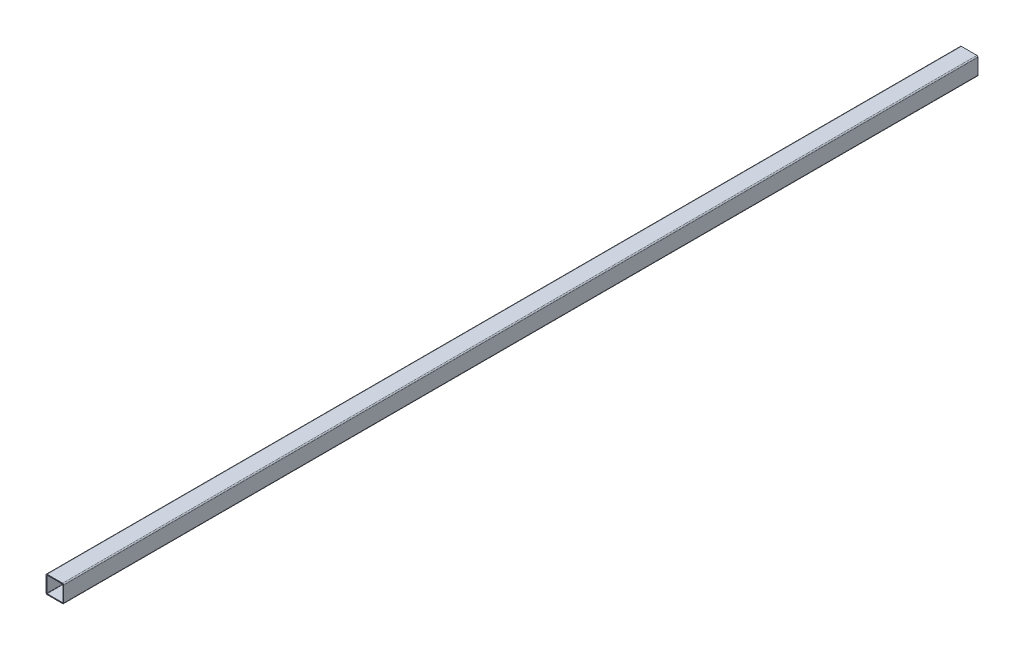
from build123d import *

# Parameters (mm, degrees)
BOSS_EXTRUDE1_DEPTH      = 825
BOSS_EXTRUDE1_DEPTH_BACK = 825


with BuildPart() as part:
    # Sketch1 → Boss-Extrude1 (new, two sides: drawn at the far end of the back side and taken through both)
    with BuildSketch(Plane.XY.offset(-BOSS_EXTRUDE1_DEPTH_BACK)):
        with BuildLine():
            Line((-14, -16), (14, -16))
            ThreePointArc((14, -16), (15.414213562, -15.414213562), (16, -14))
            Line((16, -14), (16, 14))
            ThreePointArc((16, 14), (15.414213562, 15.414213562), (14, 16))
            Line((14, 16), (-14, 16))
            ThreePointArc((-14, 16), (-15.414213562, 15.414213562), (-16, 14))
            Line((-16, 14), (-16, -14))
            ThreePointArc((-16, -14), (-15.414213562, -15.414213562), (-14, -16))
        make_face()
        with BuildLine():
            Line((-14, 14.48), (14, 14.48))
            ThreePointArc((14, 14.48), (14.339411255, 14.339411255), (14.48, 14))
            Line((14.48, 14), (14.48, -14))
            ThreePointArc((14.48, -14), (14.339411255, -14.339411255), (14, -14.48))
            Line((14, -14.48), (-14, -14.48))
            ThreePointArc((-14, -14.48), (-14.339411255, -14.339411255), (-14.48, -14))
            Line((-14.48, -14), (-14.48, 14))
            ThreePointArc((-14.48, 14), (-14.339411255, 14.339411255), (-14, 14.48))
        make_face(mode=Mode.SUBTRACT)
    extrude(amount=BOSS_EXTRUDE1_DEPTH + BOSS_EXTRUDE1_DEPTH_BACK)


solid = part.part
